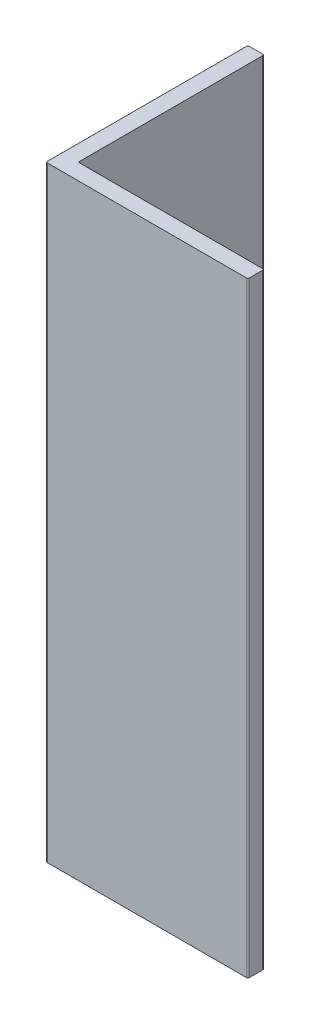
from build123d import *

# Parameters (mm, degrees)
DODANIE_WYCI_GNI_CIE1_DEPTH = 45
ZAOKR_GLENIE2_R             = 0.1


with BuildPart() as part:
    # Szkic1 → Dodanie-wyciągnięcie1 (new body)
    with BuildSketch(Plane(origin=(0, 0, 0), x_dir=(1, 0, 0), z_dir=(0, 1, 0))):
        Polygon((0, 0), (15, 0), (15, 1.2), (1.2, 1.2), (1.2, 15), (0, 15), align=None)
    extrude(amount=DODANIE_WYCI_GNI_CIE1_DEPTH)

    # Zaokrąglenie2
    zaokr_glenie2_edges = [part.edges().sort_by_distance(p)[0] for p in [
        (0, 22.5, -15),
        (1.2, 22.5, -15),
        (1.2, 22.5, -1.2),
        (15, 22.5, -1.2),
        (15, 22.5, 0),
        (0, 22.5, 0),
    ]]
    fillet(zaokr_glenie2_edges, radius=ZAOKR_GLENIE2_R)


solid = part.part
